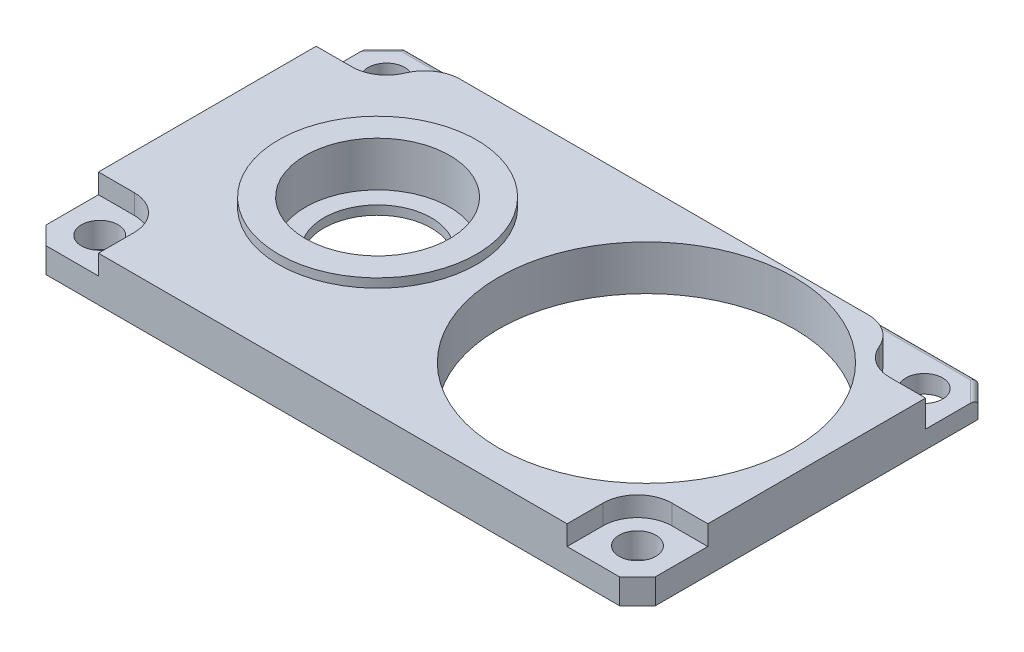
from build123d import *

# Parameters (mm, degrees)
SKETCH1_W           = 34
SKETCH1_H           = 20
BOSS_EXTRUDE1_DEPTH = 2.5
SKETCH2_R           = 3
SKETCH2_R_2         = 8.25
CUT_EXTRUDE1_DEPTH  = 5
SKETCH5_R           = 4.025
CUT_EXTRUDE4_DEPTH  = 2
SKETCH3_R           = 1.025
CUT_EXTRUDE2_DEPTH  = 4
SKETCH4_R           = 1.925
CUT_EXTRUDE3_DEPTH  = 1.5
CUT_EXTRUDE5_DEPTH  = 1.5
FILLET1_R           = 2
CHAMFER1_SIZE       = 1
FILLET2_R           = 0.3
SKETCH7_R           = 5.525
SKETCH7_R_2         = 4.025
BOSS_EXTRUDE2_DEPTH = 0.5
CUT_EXTRUDE6_DEPTH  = 1.5
SKETCH9_R           = 1.025
BOSS_EXTRUDE3_DEPTH = 0.4


with BuildPart() as part:
    # Sketch1 → Boss-Extrude1 (new body)
    with BuildSketch(Plane(origin=(0, 0, 0), x_dir=(1, 0, 0), z_dir=(0, 1, 0))):
        Rectangle(SKETCH1_W, SKETCH1_H)
    extrude(amount=BOSS_EXTRUDE1_DEPTH)

    # Sketch2 → Cut-Extrude1 (cut)
    with BuildSketch(Plane(origin=(0, 2.5, 0), x_dir=(1, 0, 0), z_dir=(0, 1, 0))):
        with Locations((-7.5, 0)):
            Circle(SKETCH2_R)
        with Locations((7.5, 0)):
            Circle(SKETCH2_R_2)
    extrude(amount=-CUT_EXTRUDE1_DEPTH, mode=Mode.SUBTRACT)

    # Sketch5 → Cut-Extrude4 (cut)
    with BuildSketch(Plane(origin=(0, 2.5, 0), x_dir=(1, 0, 0), z_dir=(0, 1, 0))):
        with Locations((-7.5, 0)):
            Circle(SKETCH5_R)
    extrude(amount=-CUT_EXTRUDE4_DEPTH, mode=Mode.SUBTRACT)

    # Sketch3 → Cut-Extrude2 (cut)
    with BuildSketch(Plane(origin=(0, 2.5, 0), x_dir=(1, 0, 0), z_dir=(0, 1, 0))):
        with Locations((15, 8)):
            Circle(SKETCH3_R)
        with Locations((-15, 8)):
            Circle(SKETCH3_R)
        with Locations((-15, -8)):
            Circle(SKETCH3_R)
        with Locations((15, -8)):
            Circle(SKETCH3_R)
    extrude(amount=-CUT_EXTRUDE2_DEPTH, mode=Mode.SUBTRACT)

    # Sketch4 → Cut-Extrude3 (cut)
    with BuildSketch(Plane(origin=(0, 2.5, 0), x_dir=(1, 0, 0), z_dir=(0, 1, 0))):
        with Locations((-15, 8)):
            Circle(SKETCH4_R)
        with Locations((-15, -8)):
            Circle(SKETCH4_R)
        with Locations((15, 8)):
            Circle(SKETCH4_R)
        with Locations((15, -8)):
            Circle(SKETCH4_R)
    extrude(amount=-CUT_EXTRUDE3_DEPTH, mode=Mode.SUBTRACT)

    # Sketch6 → Cut-Extrude5 (cut)
    with BuildSketch(Plane(origin=(0, 2.5, 0), x_dir=(1, 0, 0), z_dir=(0, 1, 0))):
        with BuildLine():
            Line((17, 10), (-17, 10))
            Line((-17, 10), (-17, 6.075))
            Line((-17, 6.075), (-15, 6.075))
            ThreePointArc((-15, 6.075), (-13.472236111, 6.828862732), (-13.141068855, 8.5))
            Line((-13.141068855, 8.5), (13.141068855, 8.5))
            ThreePointArc((13.141068855, 8.5), (13.472236111, 6.828862732), (15, 6.075))
            Line((15, 6.075), (17, 6.075))
            Line((17, 6.075), (17, 10))
        make_face()
    extrude(amount=-CUT_EXTRUDE5_DEPTH, mode=Mode.SUBTRACT)

    # Fillet1
    fillet1_edges = [part.edges().sort_by_distance(p)[0] for p in [
        (13.141068855, 1.75, -8.5),
        (-13.141068855, 1.75, -8.5),
    ]]
    fillet(fillet1_edges, radius=FILLET1_R)

    # Chamfer1
    chamfer1_edges = [part.edges().sort_by_distance(p)[0] for p in [
        (17, 1.25, 10),
        (-17, 1.25, 10),
        (-17, 0.5, -10),
        (17, 0.5, -10),
    ]]
    chamfer(chamfer1_edges, length=CHAMFER1_SIZE)

    # Fillet2
    fillet2_edges = [part.edges().sort_by_distance(p)[0] for p in [
        (0, 1, -10),
        (16.5, 1, -9.5),
        (-16.5, 1, -9.5),
    ]]
    fillet(fillet2_edges, radius=FILLET2_R)

    # Sketch7 → Boss-Extrude2 (add)
    with BuildSketch(Plane(origin=(0, 2.5, 0), x_dir=(1, 0, 0), z_dir=(0, 1, 0))):
        with Locations((-7.5, 0)):
            Circle(SKETCH7_R)
        with Locations((-7.5, 0)):
            Circle(SKETCH7_R_2, mode=Mode.SUBTRACT)
    extrude(amount=BOSS_EXTRUDE2_DEPTH)

    # Sketch8 → Cut-Extrude6 (cut)
    with BuildSketch(Plane(origin=(0, 2.5, 0), x_dir=(1, 0, 0), z_dir=(0, 1, 0))):
        with BuildLine():
            Line((-15, -6.075), (-17, -6.075))
            Line((-17, -6.075), (-17, -9))
            Line((-17, -9), (-16, -10))
            Line((-16, -10), (-13.075, -10))
            Line((-13.075, -10), (-13.075, -8))
            ThreePointArc((-13.075, -8), (-16.361180554, -9.361180554), (-15, -6.075))
        make_face()
        with BuildLine():
            Line((13.075, -10), (13.075, -8))
            ThreePointArc((13.075, -8), (16.361180554, -9.361180554), (15, -6.075))
            Line((15, -6.075), (17, -6.075))
            Line((17, -6.075), (17, -9))
            Line((17, -9), (16, -10))
            Line((16, -10), (13.075, -10))
        make_face()
    extrude(amount=-CUT_EXTRUDE6_DEPTH, mode=Mode.SUBTRACT)

    # Sketch9 → Boss-Extrude3 (add)
    with BuildSketch(Plane(origin=(0, 1, 0), x_dir=(1, 0, 0), z_dir=(0, 1, 0))):
        with BuildLine():
            Line((13.075, -8), (13.075, -10))
            Line((13.075, -10), (16, -10))
            Line((16, -10), (17, -9))
            Line((17, -9), (17, -6.075))
            Line((17, -6.075), (15, -6.075))
            ThreePointArc((15, -6.075), (13.638819446, -6.638819446), (13.075, -8))
        make_face()
        with Locations((15, -8)):
            Circle(SKETCH9_R, mode=Mode.SUBTRACT)
        with BuildLine():
            Line((-15, -6.075), (-17, -6.075))
            Line((-17, -6.075), (-17, -9))
            Line((-17, -9), (-16, -10))
            Line((-16, -10), (-13.075, -10))
            Line((-13.075, -10), (-13.075, -8))
            ThreePointArc((-13.075, -8), (-13.638819446, -6.638819446), (-15, -6.075))
        make_face()
        with Locations((-15, -8)):
            Circle(SKETCH9_R, mode=Mode.SUBTRACT)
    extrude(amount=BOSS_EXTRUDE3_DEPTH)


solid = part.part
